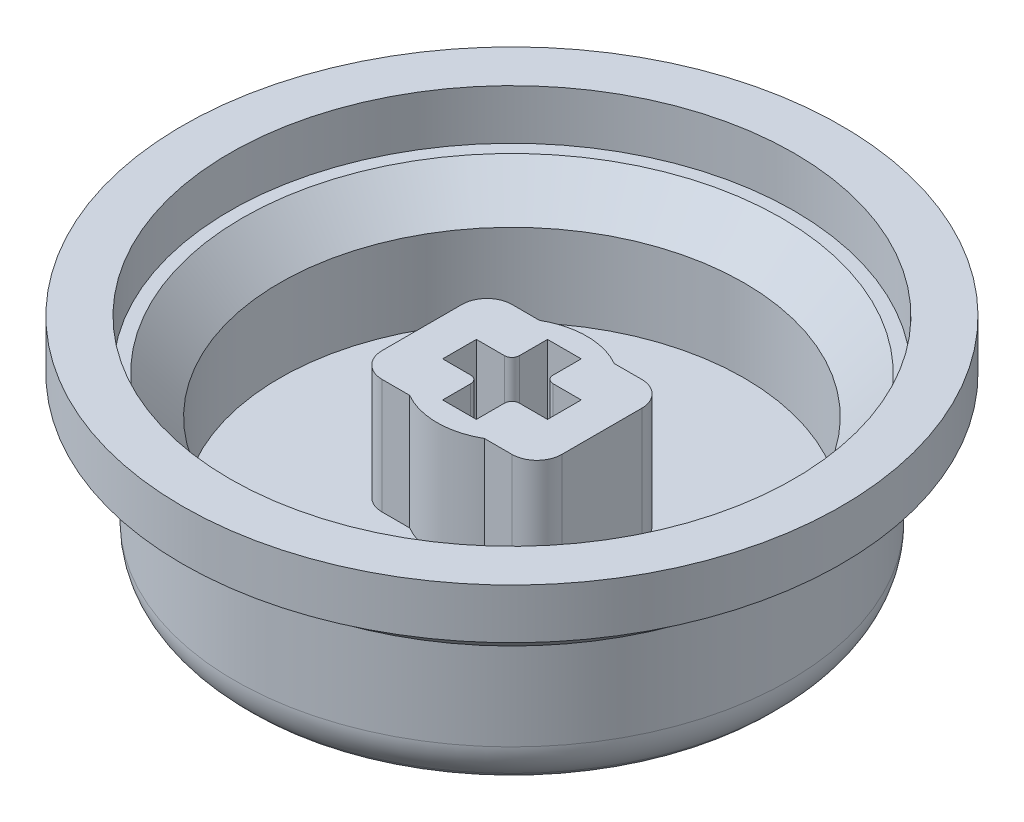
from build123d import *

# Parameters (mm, degrees)
SKETCH1_R           = 11.1
BUTTON_TOP_DEPTH    = 1.8
SKETCH2_R           = 11.1
SKETCH2_R_2         = 9.3
BUTTON_WALLS_DEPTH  = 4.8
STEM_HOUSING_DEPTH  = 4.6
CHAMFER1_SIZE       = 1.5
FILLET2_R           = 1
SKETCH8_R           = 13.2
SKETCH8_R_2         = 11.3
BOSS_EXTRUDE1_DEPTH = 2


with BuildPart() as part:
    # Sketch1 → button top (new body)
    with BuildSketch(Plane(origin=(0, 0, 0), x_dir=(1, 0, 0), z_dir=(0, 1, 0))):
        Circle(SKETCH1_R)
    extrude(amount=BUTTON_TOP_DEPTH)

    # Sketch2 → button walls (add)
    with BuildSketch(Plane(origin=(0, 1.8, 0), x_dir=(1, 0, 0), z_dir=(0, 1, 0))):
        Circle(SKETCH2_R)
        Circle(SKETCH2_R_2, mode=Mode.SUBTRACT)
    extrude(amount=BUTTON_WALLS_DEPTH)

    # Sketch3 → stem housing (add)
    with BuildSketch(Plane(origin=(0, 1.8, 0), x_dir=(1, 0, 0), z_dir=(0, 1, 0))):
        with BuildLine():
            ThreePointArc((3, 0), (2.597112711, -1.501667596), (1.496662955, -2.6))
            Line((1.496662955, -2.6), (3.6, -2.6))
            Line((3.6, -2.6), (3.6, 2.6))
            Line((3.6, 2.6), (1.496662955, 2.6))
            ThreePointArc((1.496662955, 2.6), (2.597112711, 1.501667596), (3, 0))
        make_face()
        with BuildLine():
            ThreePointArc((-1.496662955, 2.6), (-3, 0), (-1.496662955, -2.6))
            Line((-1.496662955, -2.6), (1.496662955, -2.6))
            ThreePointArc((1.496662955, -2.6), (2.597112711, -1.501667596), (3, 0))
            ThreePointArc((3, 0), (2.597112711, 1.501667596), (1.496662955, 2.6))
            Line((1.496662955, 2.6), (-1.496662955, 2.6))
        make_face()
        with BuildLine():
            ThreePointArc((-0.975, 0.675), (-0.762867966, 0.762867966), (-0.675, 0.975))
            Line((-0.675, 0.975), (-0.675, 2.1))
            Line((-0.675, 2.1), (0.675, 2.1))
            Line((0.675, 2.1), (0.675, 0.975))
            ThreePointArc((0.675, 0.975), (0.762867966, 0.762867966), (0.975, 0.675))
            Line((0.975, 0.675), (2.1, 0.675))
            Line((2.1, 0.675), (2.1, -0.675))
            Line((2.1, -0.675), (0.975, -0.675))
            ThreePointArc((0.975, -0.675), (0.762867966, -0.762867966), (0.675, -0.975))
            Line((0.675, -0.975), (0.675, -2.1))
            Line((0.675, -2.1), (-0.675, -2.1))
            Line((-0.675, -2.1), (-0.675, -0.975))
            ThreePointArc((-0.675, -0.975), (-0.762867966, -0.762867966), (-0.975, -0.675))
            Line((-0.975, -0.675), (-2.1, -0.675))
            Line((-2.1, -0.675), (-2.1, 0.675))
            Line((-2.1, 0.675), (-0.975, 0.675))
        make_face(mode=Mode.SUBTRACT)
        with BuildLine():
            Line((1.496662955, -2.6), (-1.496662955, -2.6))
            ThreePointArc((-1.496662955, -2.6), (0, -3), (1.496662955, -2.6))
        make_face()
        with BuildLine():
            Line((-3.6, 2.6), (-3.6, -2.6))
            Line((-3.6, -2.6), (-1.496662955, -2.6))
            ThreePointArc((-1.496662955, -2.6), (-3, 0), (-1.496662955, 2.6))
            Line((-1.496662955, 2.6), (-3.6, 2.6))
        make_face()
        with BuildLine():
            ThreePointArc((1.496662955, 2.6), (0, 3), (-1.496662955, 2.6))
            Line((-1.496662955, 2.6), (1.496662955, 2.6))
        make_face()
    extrude(amount=STEM_HOUSING_DEPTH)

    # Chamfer1
    chamfer1_edges = [part.edges().sort_by_distance(p)[0] for p in [
        (-9.3, 6.6, 0),
    ]]
    chamfer(chamfer1_edges, length=CHAMFER1_SIZE)

    # Fillet2
    fillet2_edges = [part.edges().sort_by_distance(p)[0] for p in [
        (3.6, 4.1, 2.6),
        (3.6, 4.1, -2.6),
        (-3.6, 4.1, -2.6),
        (-3.6, 4.1, 2.6),
    ]]
    fillet(fillet2_edges, radius=FILLET2_R)

    # Sketch6 → Cut-Revolve1 (revolve, cut)
    with BuildSketch(Plane.XY):
        with BuildLine():
            Line((-10.361522369, 0), (-10.561522369, 0.2))
            ThreePointArc((-10.561522369, 0.2), (-10.960054223, 0.79644507), (-11.1, 1.5))
            Line((-11.1, 1.5), (-11.1, 0))
            Line((-11.1, 0), (-10.361522369, 0))
        make_face()
    revolve(axis=Axis((0, 0, 0), (0, 1, 0)), mode=Mode.SUBTRACT)

    # Sketch7 → Revolve1 (revolve)
    with BuildSketch(Plane.XY):
        Polygon((11.1, 6.6), (12.7, 6.6), (11.1, 5), align=None)
    revolve(axis=Axis((0, 0, 0), (0, 1, 0)))

    # Sketch8 → Boss-Extrude1 (add)
    with BuildSketch(Plane(origin=(0, 6.6, 0), x_dir=(1, 0, 0), z_dir=(0, 1, 0))):
        Circle(SKETCH8_R)
        Circle(SKETCH8_R_2, mode=Mode.SUBTRACT)
    extrude(amount=BOSS_EXTRUDE1_DEPTH)


solid = part.part
